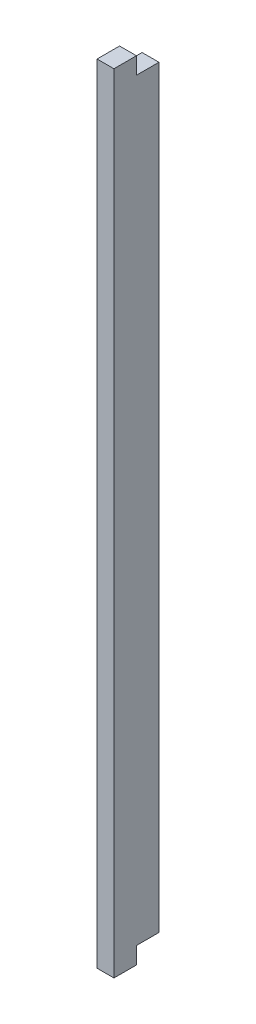
from build123d import *

# Parameters (mm, degrees)
SKETCH1_W           = 4
SKETCH1_H           = 70
BOSS_EXTRUDE1_DEPTH = 1.5
SKETCH3_W           = 2
SKETCH3_H           = 1.5
CUT_EXTRUDE1_DEPTH  = 2


with BuildPart() as part:
    # Sketch1 → Boss-Extrude1 (new body)
    with BuildSketch(Plane(origin=(0, 0, 0), x_dir=(0, 0, -1), z_dir=(1, 0, 0))):
        with Locations((-2, 4.155844156)):
            Rectangle(SKETCH1_W, SKETCH1_H)
    extrude(amount=BOSS_EXTRUDE1_DEPTH)

    # Sketch3 → Cut-Extrude1 (cut)
    with BuildSketch(Plane(origin=(1.5, 0, 0), x_dir=(0, 0, -1), z_dir=(1, 0, 0))):
        with Locations((-1, 38.405844156)):
            Rectangle(SKETCH3_W, SKETCH3_H)
        with Locations((-1, -30.094155844)):
            Rectangle(SKETCH3_W, SKETCH3_H)
    extrude(amount=-CUT_EXTRUDE1_DEPTH, mode=Mode.SUBTRACT)


solid = part.part
